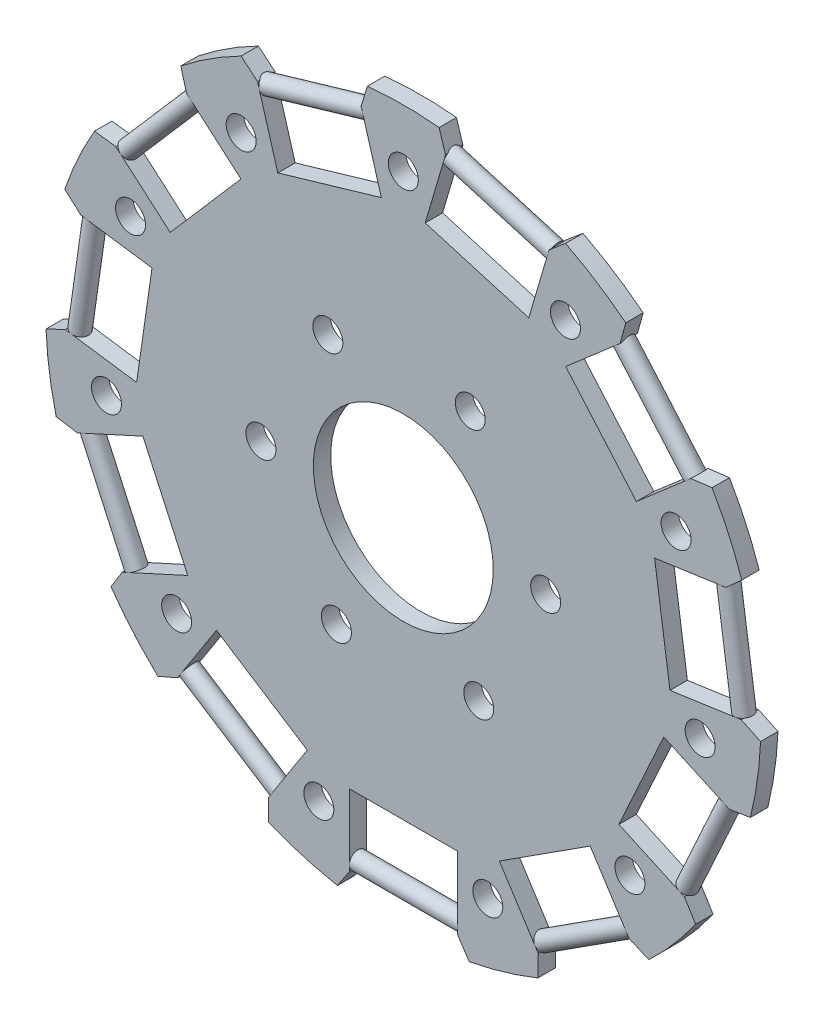
from build123d import *

# Parameters (mm, degrees)
SKETCH1_R           = 59.625
SKETCH1_R_2         = 15
BOSS_EXTRUDE1_DEPTH = 2.9
SKETCH2_R           = 2.5
CUT_EXTRUDE1_DEPTH  = 2.9
CUT_EXTRUDE2_DEPTH  = 2.9
SKETCH4_R           = 1.45
BOSS_EXTRUDE2_DEPTH = 19
CIRPATTERN1_COUNT   = 11
SKETCH6_R           = 2.5
CUT_EXTRUDE3_DEPTH  = 17


with BuildPart() as part:
    # Sketch1 → Boss-Extrude1 (new body)
    with BuildSketch(Plane.XY):
        Circle(SKETCH1_R)
        Circle(SKETCH1_R_2, mode=Mode.SUBTRACT)
    extrude(amount=BOSS_EXTRUDE1_DEPTH)

    # Sketch2 → Cut-Extrude1 (cut)
    with BuildSketch(Plane.XY.offset(2.9)):
        with Locations((0, 50)):
            Circle(SKETCH2_R)
        with Locations((27.032040873, 42.062676642)):
            Circle(SKETCH2_R)
        with Locations((45.481599768, 20.77075065)):
            Circle(SKETCH2_R)
        with Locations((49.491072094, -7.115741914)):
            Circle(SKETCH2_R)
        with Locations((37.787478718, -32.743036697)):
            Circle(SKETCH2_R)
        with Locations((14.086627842, -47.974648681)):
            Circle(SKETCH2_R)
        with Locations((-14.086627842, -47.974648681)):
            Circle(SKETCH2_R)
        with Locations((-37.787478718, -32.743036697)):
            Circle(SKETCH2_R)
        with Locations((-49.491072094, -7.115741914)):
            Circle(SKETCH2_R)
        with Locations((-45.481599768, 20.77075065)):
            Circle(SKETCH2_R)
        with Locations((-27.032040873, 42.062676642)):
            Circle(SKETCH2_R)
    extrude(amount=-CUT_EXTRUDE1_DEPTH, mode=Mode.SUBTRACT)

    # Sketch3 → Cut-Extrude2 (cut)
    with BuildSketch(Plane(origin=(0, 0, 0), x_dir=(-1, 0, 0), z_dir=(0, 0, -1))):
        Polygon((50.956409033, 32.242596102), (39.169377411, 45.846488396), (37.103935437, 46.703196894), (36.146290235, 43.227148035), (27.077028706, 35.369126954), (38.864060328, 21.76523466), (47.933321857, 29.623255742), (51.51030742, 30.076217424), align=None)
        Polygon((25.435595606, 54.673312513), (8.164894162, 59.745084554), (5.964162221, 59.349131367), (7.037833709, 55.907150899), (3.656652348, 44.393349937), (20.927353792, 39.321577896), (24.308535153, 50.835378859), (27.07279732, 53.150298873), align=None)
        Polygon((60.298922633, -0.424916756), (57.73786009, 17.391956108), (56.463471315, 19.229327396), (53.778555009, 16.822831099), (41.900639766, 15.115456069), (44.46170231, -2.701416795), (56.339617553, -0.994041765), (59.593658868, -2.546850548), align=None)
        Polygon((50.496954349, -32.957521546), (57.974980146, -16.584399358), (57.896254002, -14.349717682), (54.336508549, -14.922615848), (43.421093757, -9.937265316), (35.94306796, -26.310387504), (46.858482752, -31.295738036), (48.756444695, -34.361311467), align=None)
        Polygon((24.662559854, -55.026346112), (39.805453638, -45.295325208), (40.947385119, -43.372828786), (37.643004548, -41.9302377), (31.155657278, -31.834975178), (16.012763494, -41.565996082), (22.500110764, -51.661258605), (22.439403827, -55.26629878), align=None)
        Polygon((-9.002023138, -59.624694586), (8.997976851, -59.625305346), (10.998010781, -58.625373209), (8.998112576, -55.625305348), (8.998519749, -43.625305355), (-9.00148024, -43.624694595), (-9.001887414, -55.624694588), (-11.001989206, -58.624626724), align=None)
        Polygon((-39.808527389, -45.292623816), (-24.666294009, -55.024672329), (-22.443154271, -55.264775865), (-22.503616561, -51.659731577), (-16.01558422, -41.564909324), (-31.1578176, -31.832860811), (-37.645849942, -41.927683065), (-40.950328403, -43.370049904), align=None)
        Polygon((-57.976105467, -16.580465007), (-50.499190805, -32.954094633), (-48.758776418, -34.358002666), (-46.860606443, -31.292558041), (-35.944853359, -26.307948266), (-43.421768022, -9.93431864), (-54.337521106, -14.918928415), (-57.897227673, -14.345788678), align=None)
        Polygon((-57.736679699, 17.39587429), (-60.29895133, -0.420824734), (-59.593831566, -2.542806382), (-56.339684881, -0.990218429), (-44.461885532, -2.698399517), (-41.899613901, 15.118299506), (-53.77741325, 16.826480594), (-56.462166239, 19.233159091), align=None)
        Polygon((-39.166266075, 45.849146413), (-50.954220861, 32.246054045), (-51.508266261, 30.079712961), (-47.931311446, 29.626508537), (-38.862583201, 21.767872013), (-27.074628415, 35.370964381), (-36.14335666, 43.229600905), (-37.100765967, 46.705714743), align=None)
        Polygon((-8.160839707, 59.745638504), (-25.431885293, 54.675038504), (-27.069190358, 53.152135972), (-24.305085293, 50.837028374), (-20.924685293, 39.322997983), (-3.653639707, 44.393597983), (-7.034039707, 55.907628374), (-5.960134642, 59.349535972), align=None)
    extrude(amount=-CUT_EXTRUDE2_DEPTH, mode=Mode.SUBTRACT)

    # Sketch4 → Boss-Extrude2 (add)
    with BuildSketch(Plane(origin=(8.635350722, 2.53588602, 0), x_dir=(0, 0, 1), z_dir=(-0.959483414, -0.281765113, 0))):
        with Locations((1.45, 54.625)):
            Circle(SKETCH4_R)
    boss_extrude2 = extrude(amount=BOSS_EXTRUDE2_DEPTH)

    # CirPattern1: Boss-Extrude2 ×11 about axis
    cirpattern1_axis = Axis((0, 0, 0), (0, 0, 1))
    for i in range(1, CIRPATTERN1_COUNT):
        add(boss_extrude2.rotate(cirpattern1_axis, i * 360 / CIRPATTERN1_COUNT))

    # Sketch6 → Cut-Extrude3 (cut)
    with BuildSketch(Plane.XY.offset(2.9)):
        with Locations((11.156714618, 20.966406915)):
            Circle(SKETCH6_R)
        with Locations((23.735798324, 0.821205176)):
            Circle(SKETCH6_R)
        with Locations((12.579083706, -20.14520174)):
            Circle(SKETCH6_R)
        with Locations((-11.156714618, -20.966406915)):
            Circle(SKETCH6_R)
        with Locations((-23.735798324, -0.821205176)):
            Circle(SKETCH6_R)
        with Locations((-12.579083706, 20.14520174)):
            Circle(SKETCH6_R)
    extrude(amount=-CUT_EXTRUDE3_DEPTH, mode=Mode.SUBTRACT)


solid = part.part
